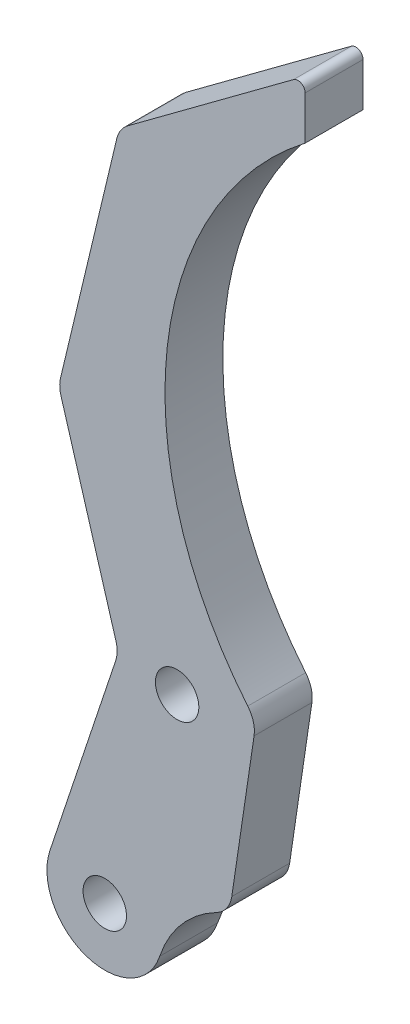
from build123d import *

# Parameters (mm, degrees)
SKETCH_1_R      = 1.5
EXTRUDE_1_DEPTH = 4


with BuildPart() as part:
    # 草图1 → 凸台-拉伸1 (new body)
    with BuildSketch(Plane.XY):
        with BuildLine():
            Line((-8.883361298, 38.430372232), (-10.42356995, 28.043950456))
            ThreePointArc((-10.42356995, 28.043950456), (-10.775128008, 27.17392517), (-11.484802252, 26.560003729))
            ThreePointArc((-11.484802252, 26.560003729), (-13.893149851, 24.653752275), (-15.405733358, 21.980547476))
            ThreePointArc((-15.405733358, 21.980547476), (-20.465380085, 19.450724806), (-22.995202754, 24.510371532))
            Line((-22.995202754, 24.510371532), (-18.451197233, 38.142383115))
            ThreePointArc((-18.451197233, 38.142383115), (-18.348830032, 38.742204214), (-18.431570381, 39.345046174))
            Line((-18.431570381, 39.345046174), (-22.233001172, 52.125165651))
            ThreePointArc((-22.233001172, 52.125165651), (-22.31526172, 52.64074939), (-22.261276417, 53.160055635))
            Line((-22.261276417, 53.160055635), (-18.372774426, 69.438220218))
            ThreePointArc((-18.372774426, 69.438220218), (-18.096529541, 70.075517478), (-17.618975762, 70.579899696))
            Line((-17.618975762, 70.579899696), (-6.150614111, 79.086205979))
            ThreePointArc((-6.150614111, 79.086205979), (-5.627950875, 79.131232586), (-5.352746621, 78.684615443))
            Line((-5.352746621, 78.684615443), (-5.352746621, 75.677999772))
            ThreePointArc((-5.352746621, 75.677999772), (-14.888864346, 58.677248629), (-9.31952103, 39.997165768))
            ThreePointArc((-9.31952103, 39.997165768), (-8.934989705, 39.260105305), (-8.883361298, 38.430372232))
        make_face()
        with Locations((-19.200468056, 23.245459504)):
            Circle(SKETCH_1_R, mode=Mode.SUBTRACT)
        with Locations((-14.200468056, 38.245459504)):
            Circle(SKETCH_1_R, mode=Mode.SUBTRACT)
    extrude(amount=EXTRUDE_1_DEPTH)


solid = part.part
